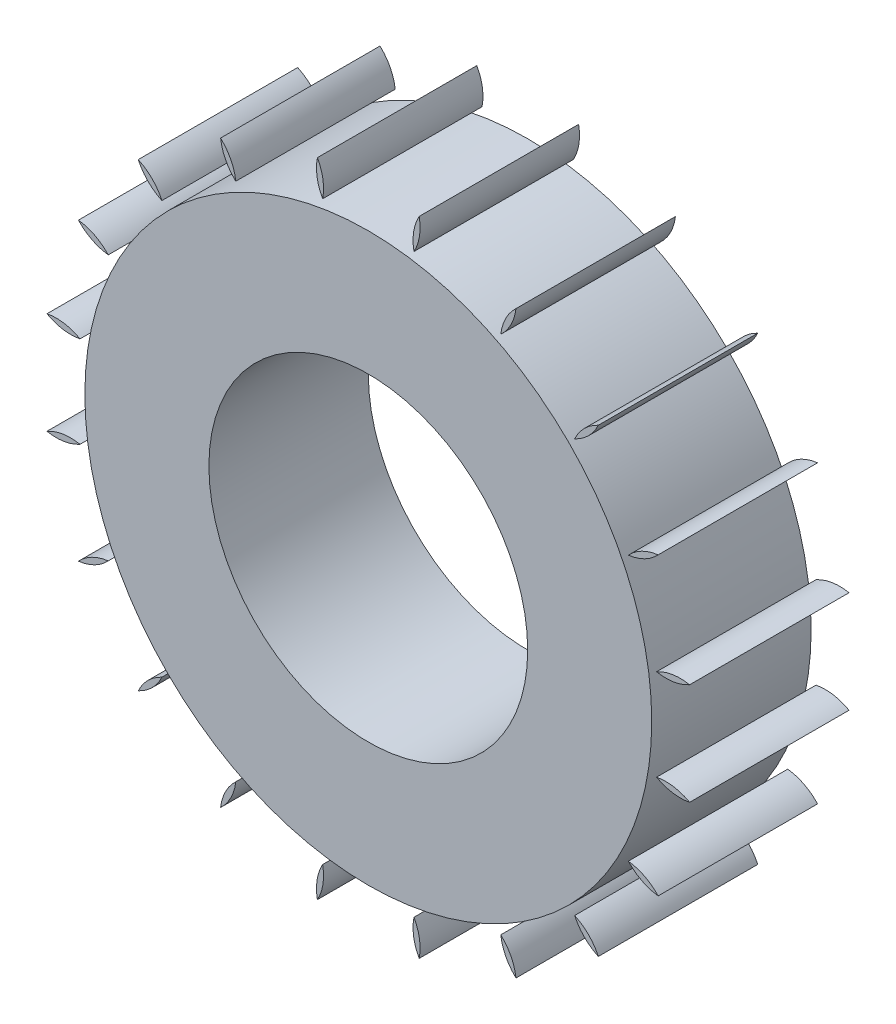
from build123d import *

# Parameters (mm, degrees)
SKETCH1_R           = 13.2
SKETCH1_R_2         = 6
BOSS_EXTRUDE1_DEPTH = 6
CUT_EXTRUDE1_DEPTH  = 7
CIRPATTERN3_COUNT   = 20


with BuildPart() as part:
    # Sketch1 → Boss-Extrude1 (new body)
    with BuildSketch(Plane.XY):
        Circle(SKETCH1_R)
        Circle(SKETCH1_R_2, mode=Mode.SUBTRACT)
    extrude(amount=BOSS_EXTRUDE1_DEPTH)

    # Sketch2 → Cut-Extrude1 (cut, through all)
    with BuildSketch(Plane.XY.offset(6)):
        with BuildLine():
            ThreePointArc((-2.819851171, 12.895287487), (0, 13.2), (2.819851171, 12.895287487))
            ThreePointArc((2.819851171, 12.895287487), (1.826256171, 11.910750525), (1.819851171, 10.512))
            ThreePointArc((1.819851171, 10.512), (0, 10.668364555), (-1.819851171, 10.512))
            ThreePointArc((-1.819851171, 10.512), (-1.826256171, 11.910750525), (-2.819851171, 12.895287487))
        make_face()
    cut_extrude1 = extrude(amount=-CUT_EXTRUDE1_DEPTH, mode=Mode.SUBTRACT)

    # CirPattern3: Cut-Extrude1 ×20 about axis
    cirpattern3_axis = Axis((0, 0, 0), (0, 0, 1))
    for i in range(1, CIRPATTERN3_COUNT):
        add(cut_extrude1.rotate(cirpattern3_axis, i * 360 / CIRPATTERN3_COUNT), mode=Mode.SUBTRACT)


solid = part.part
